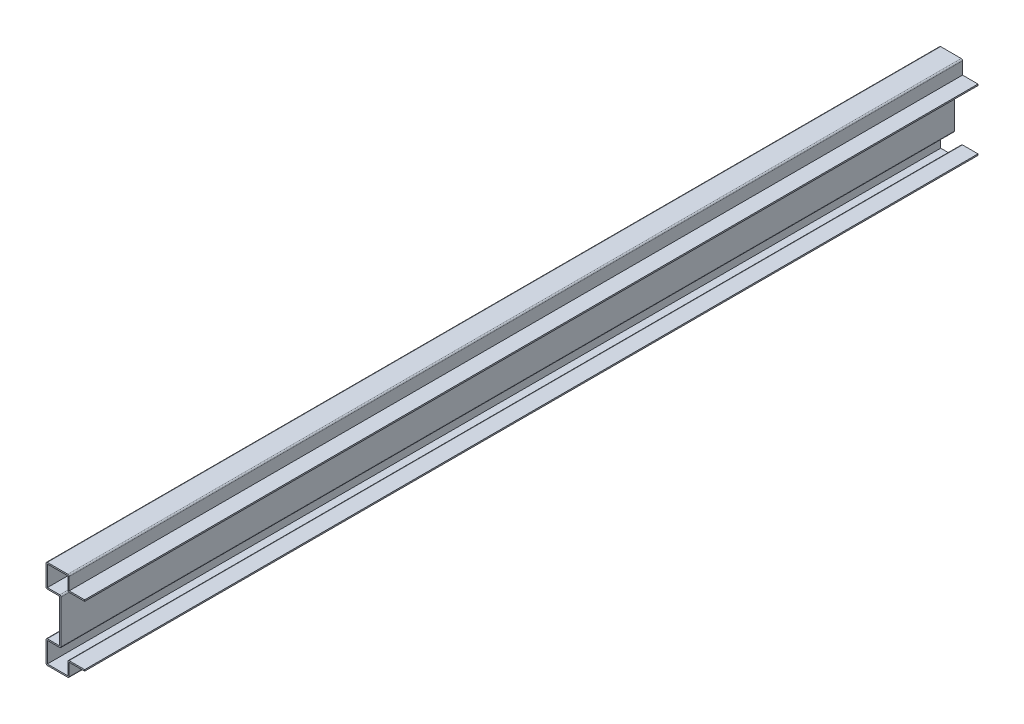
from build123d import *

# Parameters (mm, degrees)
BOSS_EXTRUDE1_DEPTH = 825.5
FILLET1_R           = 1.27


with BuildPart() as part:
    # Sketch1 → Boss-Extrude1 (new body)
    with BuildSketch(Plane.XY):
        Polygon((0, 12.7), (-14.2875, 12.7), (-14.2875, 0), (-35.71875, 0), (-35.71875, 21.43125), (-23.01875, 21.43125), (-23.01875, 61.11875), (-35.71875, 61.11875), (-35.71875, 82.55), (-14.2875, 82.55), (-14.2875, 69.85), (0, 69.85), (0, 68.58), (-15.5575, 68.58), (-15.5575, 81.28), (-34.44875, 81.28), (-34.44875, 62.38875), (-21.74875, 62.38875), (-21.74875, 20.16125), (-34.44875, 20.16125), (-34.44875, 1.27), (-15.5575, 1.27), (-15.5575, 13.97), (0, 13.97), align=None)
    extrude(amount=-BOSS_EXTRUDE1_DEPTH)

    # Fillet1
    fillet1_edges = [part.edges().sort_by_distance(p)[0] for p in [
        (-14.2875, 0, -412.75),
        (-35.71875, 0, -412.75),
        (-35.71875, 21.43125, -412.75),
        (-35.71875, 61.11875, -412.75),
        (-35.71875, 82.55, -412.75),
        (-14.2875, 82.55, -412.75),
        (-15.5575, 68.58, -412.75),
        (-21.74875, 62.38875, -412.75),
        (-21.74875, 20.16125, -412.75),
        (-15.5575, 13.97, -412.75),
    ]]
    fillet(fillet1_edges, radius=FILLET1_R)


solid = part.part
